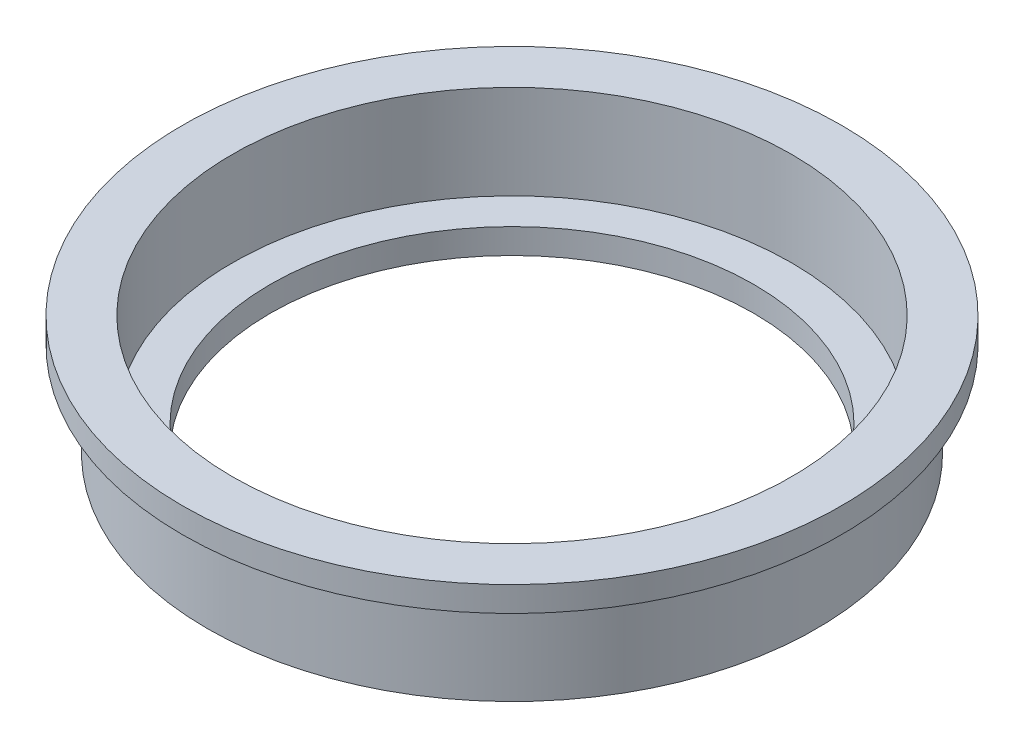
from build123d import *


with BuildPart() as part:
    # Sketch1 → Revolve1 (revolve)
    with BuildSketch(Plane.XY):
        Polygon((24.511, 0), (24.511, 2.54), (28.321, 2.54), (28.321, 12.065), (33.401, 12.065), (33.401, 9.525), (30.861, 9.525), (30.861, 0), align=None)
    revolve(axis=Axis((0, 0, 0), (0, 1, 0)))


solid = part.part
